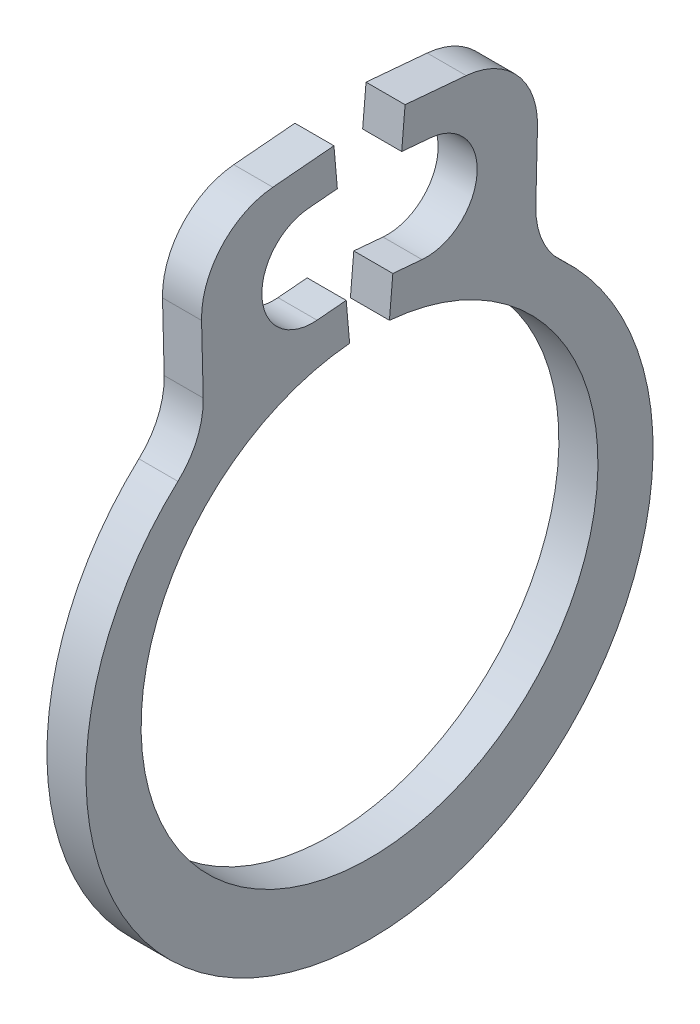
from build123d import *

# Parameters (mm, degrees)
EXTRUDE1_DEPTH = 0.127
FILLET1_R      = 0.508


with BuildPart() as part:
    # Sketch1 → Extrude1 (new body, symmetric)
    with BuildSketch(Plane(origin=(0, 0, 0), x_dir=(0, 0, -1), z_dir=(1, 0, 0))):
        with BuildLine():
            Line((0.231337488, 2.644199587), (1.104302902, 2.56782501))
            Line((1.104302902, 2.56782501), (1.075595843, 1.399777723))
            ThreePointArc((1.075595843, 1.399777723), (0, -1.9431), (-1.075595843, 1.399777723))
            Line((-1.075595843, 1.399777723), (-1.104302902, 2.56782501))
            Line((-1.104302902, 2.56782501), (-0.231337488, 2.644199587))
            Line((-0.231337488, 2.644199587), (-0.209199929, 2.391166134))
            Line((-0.209199929, 2.391166134), (-0.398975019, 2.374562965))
            ThreePointArc((-0.398975019, 2.374562965), (-0.699139682, 2.016840649), (-0.341417367, 1.716675986))
            Line((-0.341417367, 1.716675986), (-0.151642277, 1.733279155))
            Line((-0.151642277, 1.733279155), (-0.129504718, 1.480245702))
            ThreePointArc((-0.129504718, 1.480245702), (0, -1.4859), (0.129504718, 1.480245702))
            Line((0.129504718, 1.480245702), (0.151642277, 1.733279155))
            Line((0.151642277, 1.733279155), (0.341417367, 1.716675986))
            ThreePointArc((0.341417367, 1.716675986), (0.699139682, 2.016840649), (0.398975019, 2.374562965))
            Line((0.398975019, 2.374562965), (0.209199929, 2.391166134))
            Line((0.209199929, 2.391166134), (0.231337488, 2.644199587))
        make_face()
    extrude(amount=EXTRUDE1_DEPTH, both=True)

    # Fillet1
    fillet1_edges = [part.edges().sort_by_distance(p)[0] for p in [
        (0, 2.56782501, -1.104302902),
        (0, 1.399777723, -1.075595843),
        (0, 1.399777723, 1.075595843),
        (0, 2.56782501, 1.104302902),
    ]]
    fillet(fillet1_edges, radius=FILLET1_R)


solid = part.part
